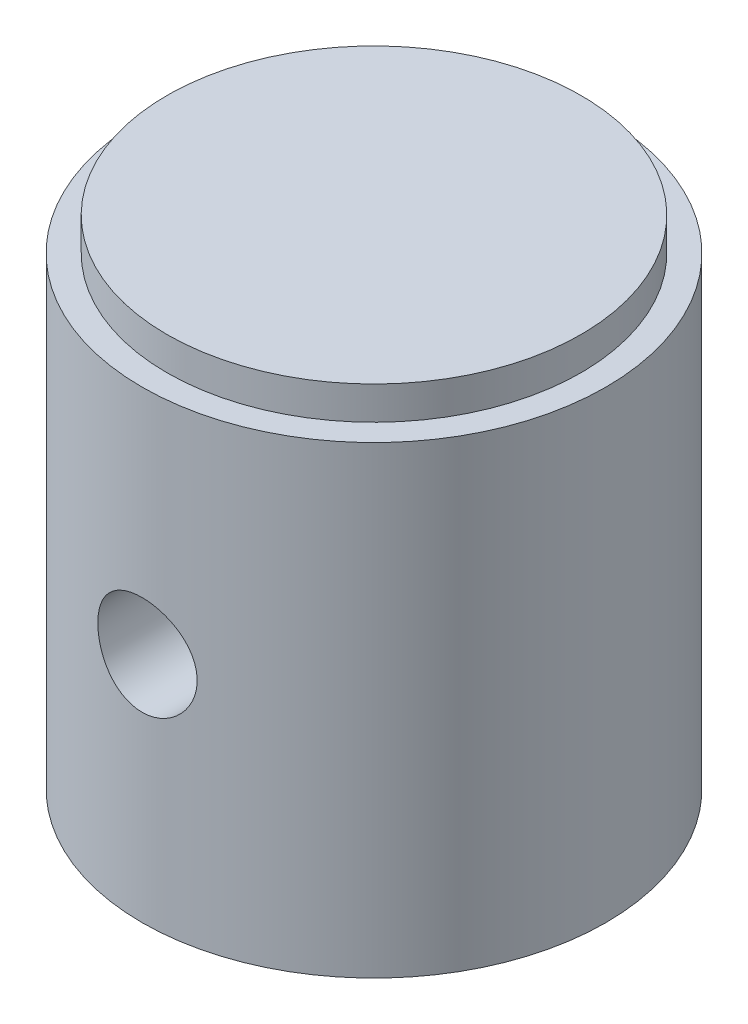
from build123d import *

# Parameters (mm, degrees)
SKETCH2_R               = 1.5
CUT_EXTRUDE1_DEPTH      = 8
CUT_EXTRUDE1_DEPTH_BACK = 8


with BuildPart() as part:
    # Sketch1 → Revolve1 (revolve)
    with BuildSketch(Plane.XY):
        Polygon((-7, 0), (-6.25, 0), (-4.75, 4.121216129), (-4.75, 11), (0, 13.85408794), (0, 15), (-6.25, 15), (-6.25, 14), (-7, 14), align=None)
    revolve(axis=Axis((0, 19.367113744, 0), (0, -1, 0)))

    # Sketch2 → Cut-Extrude1 (cut, two sides)
    with BuildSketch(Plane.XY) as cut_extrude1_sk:
        with Locations((0, 7)):
            Circle(SKETCH2_R)
    extrude(amount=CUT_EXTRUDE1_DEPTH, mode=Mode.SUBTRACT)
    extrude(cut_extrude1_sk.sketch, amount=-CUT_EXTRUDE1_DEPTH_BACK, mode=Mode.SUBTRACT)


solid = part.part
